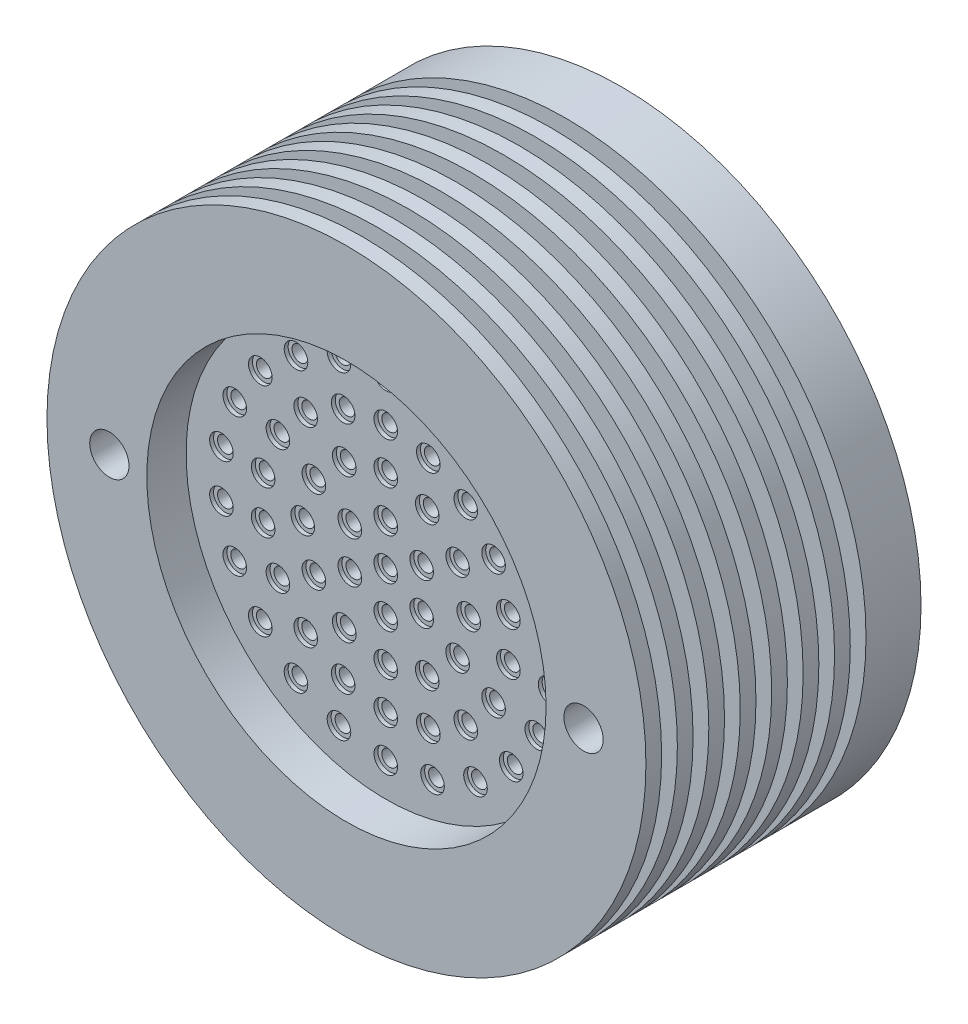
from build123d import *

# Parameters (mm, degrees)
ESQUISSE2_R                = 38.1
BOSS_EXTRU_1_DEPTH         = 35
ESQUISSE3_R                = 25.4
ENL_V_MAT_EXTRU_1_DEPTH    = 5
ESQUISSE4_R                = 25.4
ENL_V_MAT_EXTRU_2_DEPTH    = 25
ESQUISSE5_R                = 1
ENL_V_MAT_EXTRU_3_DEPTH    = 5
ESQUISSE6_R                = 1.5
ENL_V_MAT_EXTRU_4_DEPTH    = 0.5
ESQUISSE7_R                = 38.1
ESQUISSE7_R_2              = 34.925
ENL_V_MAT_EXTRU_5_DEPTH    = 2
R_P_TITION_LIN_AIRE1_COUNT = 7
R_P_TITION_LIN_AIRE1_PITCH = 4
ESQUISSE8_R                = 2.5
ENL_V_MAT_EXTRU_6_DEPTH    = 36


with BuildPart() as part:
    # Esquisse2 → Boss.-Extru.1 (new body)
    with BuildSketch(Plane.XY):
        with Locations((31.739876627, 14.618781351)):
            Circle(ESQUISSE2_R)
    extrude(amount=BOSS_EXTRU_1_DEPTH)

    # Esquisse3 → Enlèv. mat.-Extru.1 (cut)
    with BuildSketch(Plane.XY.offset(35)):
        with Locations((31.739876627, 14.618781351)):
            Circle(ESQUISSE3_R)
    extrude(amount=-ENL_V_MAT_EXTRU_1_DEPTH, mode=Mode.SUBTRACT)

    # Esquisse4 → Enlèv. mat.-Extru.2 (cut)
    with BuildSketch(Plane(origin=(0, 0, 0), x_dir=(-1, 0, 0), z_dir=(0, 0, -1))):
        with Locations((-31.739876627, 14.618781351)):
            Circle(ESQUISSE4_R)
    extrude(amount=-ENL_V_MAT_EXTRU_2_DEPTH, mode=Mode.SUBTRACT)

    # Esquisse5 → Enlèv. mat.-Extru.3 (cut)
    with BuildSketch(Plane.XY.offset(30)):
        with Locations((31.739876627, 14.618781351)):
            Circle(ESQUISSE5_R)
        with Locations((31.739876627, 19.898781351)):
            Circle(ESQUISSE5_R)
        with Locations((36.312490759, 17.258781351)):
            Circle(ESQUISSE5_R)
        with Locations((36.312490759, 11.978781351)):
            Circle(ESQUISSE5_R)
        with Locations((31.739876627, 9.338781351)):
            Circle(ESQUISSE5_R)
        with Locations((27.167262495, 11.978781351)):
            Circle(ESQUISSE5_R)
        with Locations((27.167262495, 17.258781351)):
            Circle(ESQUISSE5_R)
        with Locations((31.739876627, 25.178781351)):
            Circle(ESQUISSE5_R)
        with Locations((37.019876627, 23.764009615)):
            Circle(ESQUISSE5_R)
        with Locations((40.885104891, 19.898781351)):
            Circle(ESQUISSE5_R)
        with Locations((42.299876627, 14.618781351)):
            Circle(ESQUISSE5_R)
        with Locations((40.885104891, 9.338781351)):
            Circle(ESQUISSE5_R)
        with Locations((37.019876627, 5.473553087)):
            Circle(ESQUISSE5_R)
        with Locations((31.739876627, 4.058781351)):
            Circle(ESQUISSE5_R)
        with Locations((26.459876627, 5.473553087)):
            Circle(ESQUISSE5_R)
        with Locations((22.594648363, 9.338781351)):
            Circle(ESQUISSE5_R)
        with Locations((21.179876627, 14.618781351)):
            Circle(ESQUISSE5_R)
        with Locations((22.594648363, 19.898781351)):
            Circle(ESQUISSE5_R)
        with Locations((26.459876627, 23.764009615)):
            Circle(ESQUISSE5_R)
        with Locations((31.739876627, 30.458781351)):
            Circle(ESQUISSE5_R)
        with Locations((37.157475698, 29.503512464)):
            Circle(ESQUISSE5_R)
        with Locations((41.921632365, 26.75292533)):
            Circle(ESQUISSE5_R)
        with Locations((45.457719023, 22.538781351)):
            Circle(ESQUISSE5_R)
        with Locations((47.339231435, 17.369368485)):
            Circle(ESQUISSE5_R)
        with Locations((47.339231435, 11.868194217)):
            Circle(ESQUISSE5_R)
        with Locations((45.457719023, 6.698781351)):
            Circle(ESQUISSE5_R)
        with Locations((41.921632365, 2.484637372)):
            Circle(ESQUISSE5_R)
        with Locations((37.157475698, -0.265949762)):
            Circle(ESQUISSE5_R)
        with Locations((31.739876627, -1.221218649)):
            Circle(ESQUISSE5_R)
        with Locations((26.322277557, -0.265949762)):
            Circle(ESQUISSE5_R)
        with Locations((21.55812089, 2.484637372)):
            Circle(ESQUISSE5_R)
        with Locations((18.022034231, 6.698781351)):
            Circle(ESQUISSE5_R)
        with Locations((16.14052182, 11.868194217)):
            Circle(ESQUISSE5_R)
        with Locations((16.14052182, 17.369368485)):
            Circle(ESQUISSE5_R)
        with Locations((18.022034231, 22.538781351)):
            Circle(ESQUISSE5_R)
        with Locations((21.55812089, 26.75292533)):
            Circle(ESQUISSE5_R)
        with Locations((26.322277557, 29.503512464)):
            Circle(ESQUISSE5_R)
        with Locations((31.739876627, 35.738781351)):
            Circle(ESQUISSE5_R)
        with Locations((37.690068228, 34.883272954)):
            Circle(ESQUISSE5_R)
        with Locations((43.158210692, 32.386055965)):
            Circle(ESQUISSE5_R)
        with Locations((47.701307638, 28.449440052)):
            Circle(ESQUISSE5_R)
        with Locations((50.951304369, 23.392346426)):
            Circle(ESQUISSE5_R)
        with Locations((52.64490548, 17.624470735)):
            Circle(ESQUISSE5_R)
        with Locations((52.64490548, 11.613091967)):
            Circle(ESQUISSE5_R)
        with Locations((50.951304369, 5.845216277)):
            Circle(ESQUISSE5_R)
        with Locations((47.701307638, 0.78812265)):
            Circle(ESQUISSE5_R)
        with Locations((43.158210692, -3.148493262)):
            Circle(ESQUISSE5_R)
        with Locations((37.690068228, -5.645710252)):
            Circle(ESQUISSE5_R)
        with Locations((31.739876627, -6.501218649)):
            Circle(ESQUISSE5_R)
        with Locations((25.789685027, -5.645710252)):
            Circle(ESQUISSE5_R)
        with Locations((20.321542563, -3.148493262)):
            Circle(ESQUISSE5_R)
        with Locations((15.778445617, 0.78812265)):
            Circle(ESQUISSE5_R)
        with Locations((12.528448885, 5.845216277)):
            Circle(ESQUISSE5_R)
        with Locations((10.834847775, 11.613091967)):
            Circle(ESQUISSE5_R)
        with Locations((10.834847775, 17.624470735)):
            Circle(ESQUISSE5_R)
        with Locations((12.528448885, 23.392346426)):
            Circle(ESQUISSE5_R)
        with Locations((15.778445617, 28.449440052)):
            Circle(ESQUISSE5_R)
        with Locations((20.321542563, 32.386055965)):
            Circle(ESQUISSE5_R)
        with Locations((25.789685027, 34.883272954)):
            Circle(ESQUISSE5_R)
    extrude(amount=-ENL_V_MAT_EXTRU_3_DEPTH, mode=Mode.SUBTRACT)

    # Esquisse6 → Enlèv. mat.-Extru.4 (cut)
    with BuildSketch(Plane.XY.offset(30)):
        with Locations((31.739876627, 14.618781351)):
            Circle(ESQUISSE6_R)
        with Locations((31.739876627, 19.898781351)):
            Circle(ESQUISSE6_R)
        with Locations((36.312490759, 17.258781351)):
            Circle(ESQUISSE6_R)
        with Locations((36.312490759, 11.978781351)):
            Circle(ESQUISSE6_R)
        with Locations((31.739876627, 9.338781351)):
            Circle(ESQUISSE6_R)
        with Locations((27.167262495, 11.978781351)):
            Circle(ESQUISSE6_R)
        with Locations((27.167262495, 17.258781351)):
            Circle(ESQUISSE6_R)
        with Locations((31.739876627, 25.178781351)):
            Circle(ESQUISSE6_R)
        with Locations((37.019876627, 23.764009615)):
            Circle(ESQUISSE6_R)
        with Locations((40.885104891, 19.898781351)):
            Circle(ESQUISSE6_R)
        with Locations((42.299876627, 14.618781351)):
            Circle(ESQUISSE6_R)
        with Locations((40.885104891, 9.338781351)):
            Circle(ESQUISSE6_R)
        with Locations((37.019876627, 5.473553087)):
            Circle(ESQUISSE6_R)
        with Locations((31.739876627, 4.058781351)):
            Circle(ESQUISSE6_R)
        with Locations((26.459876627, 5.473553087)):
            Circle(ESQUISSE6_R)
        with Locations((22.594648363, 9.338781351)):
            Circle(ESQUISSE6_R)
        with Locations((21.179876627, 14.618781351)):
            Circle(ESQUISSE6_R)
        with Locations((22.594648363, 19.898781351)):
            Circle(ESQUISSE6_R)
        with Locations((26.459876627, 23.764009615)):
            Circle(ESQUISSE6_R)
        with Locations((31.739876627, 30.458781351)):
            Circle(ESQUISSE6_R)
        with Locations((31.739876627, 35.738781351)):
            Circle(ESQUISSE6_R)
        with Locations((37.690068228, 34.883272954)):
            Circle(ESQUISSE6_R)
        with Locations((43.158210692, 32.386055965)):
            Circle(ESQUISSE6_R)
        with Locations((47.701307638, 28.449440052)):
            Circle(ESQUISSE6_R)
        with Locations((50.951304369, 23.392346426)):
            Circle(ESQUISSE6_R)
        with Locations((52.64490548, 17.624470735)):
            Circle(ESQUISSE6_R)
        with Locations((52.64490548, 11.613091967)):
            Circle(ESQUISSE6_R)
        with Locations((50.951304369, 5.845216277)):
            Circle(ESQUISSE6_R)
        with Locations((47.701307638, 0.78812265)):
            Circle(ESQUISSE6_R)
        with Locations((43.158210692, -3.148493262)):
            Circle(ESQUISSE6_R)
        with Locations((37.690068228, -5.645710252)):
            Circle(ESQUISSE6_R)
        with Locations((31.739876627, -6.501218649)):
            Circle(ESQUISSE6_R)
        with Locations((25.789685027, -5.645710252)):
            Circle(ESQUISSE6_R)
        with Locations((20.321542563, -3.148493262)):
            Circle(ESQUISSE6_R)
        with Locations((15.778445617, 0.78812265)):
            Circle(ESQUISSE6_R)
        with Locations((12.528448885, 5.845216277)):
            Circle(ESQUISSE6_R)
        with Locations((10.834847775, 11.613091967)):
            Circle(ESQUISSE6_R)
        with Locations((10.834847775, 17.624470735)):
            Circle(ESQUISSE6_R)
        with Locations((12.528448885, 23.392346426)):
            Circle(ESQUISSE6_R)
        with Locations((15.778445617, 28.449440052)):
            Circle(ESQUISSE6_R)
        with Locations((20.321542563, 32.386055965)):
            Circle(ESQUISSE6_R)
        with Locations((25.789685027, 34.883272954)):
            Circle(ESQUISSE6_R)
        with Locations((37.157475698, 29.503512464)):
            Circle(ESQUISSE6_R)
        with Locations((41.921632365, 26.75292533)):
            Circle(ESQUISSE6_R)
        with Locations((45.457719023, 22.538781351)):
            Circle(ESQUISSE6_R)
        with Locations((47.339231435, 17.369368485)):
            Circle(ESQUISSE6_R)
        with Locations((47.339231435, 11.868194217)):
            Circle(ESQUISSE6_R)
        with Locations((45.457719023, 6.698781351)):
            Circle(ESQUISSE6_R)
        with Locations((41.921632365, 2.484637372)):
            Circle(ESQUISSE6_R)
        with Locations((37.157475698, -0.265949762)):
            Circle(ESQUISSE6_R)
        with Locations((31.739876627, -1.221218649)):
            Circle(ESQUISSE6_R)
        with Locations((26.322277557, -0.265949762)):
            Circle(ESQUISSE6_R)
        with Locations((21.55812089, 2.484637372)):
            Circle(ESQUISSE6_R)
        with Locations((18.022034231, 6.698781351)):
            Circle(ESQUISSE6_R)
        with Locations((16.14052182, 11.868194217)):
            Circle(ESQUISSE6_R)
        with Locations((16.14052182, 17.369368485)):
            Circle(ESQUISSE6_R)
        with Locations((18.022034231, 22.538781351)):
            Circle(ESQUISSE6_R)
        with Locations((21.55812089, 26.75292533)):
            Circle(ESQUISSE6_R)
        with Locations((26.322277557, 29.503512464)):
            Circle(ESQUISSE6_R)
    extrude(amount=-ENL_V_MAT_EXTRU_4_DEPTH, mode=Mode.SUBTRACT)

    # Esquisse7 → Enlèv. mat.-Extru.5 (cut)
    with BuildSketch(Plane.XY.offset(33)):
        with Locations((31.739876627, 14.618781351)):
            Circle(ESQUISSE7_R)
        with Locations((31.739876627, 14.618781351)):
            Circle(ESQUISSE7_R_2, mode=Mode.SUBTRACT)
    enl_v_mat_extru_5 = extrude(amount=-ENL_V_MAT_EXTRU_5_DEPTH, mode=Mode.SUBTRACT)

    # Répétition linéaire1: Enlèv. mat.-Extru.5 ×7
    with Locations(*[(0, 0, -i * R_P_TITION_LIN_AIRE1_PITCH) for i in range(1, R_P_TITION_LIN_AIRE1_COUNT)]):
        add(enl_v_mat_extru_5, mode=Mode.SUBTRACT)

    # Esquisse8 → Enlèv. mat.-Extru.6 (cut, through all)
    with BuildSketch(Plane(origin=(0, 0, 0), x_dir=(-1, 0, 0), z_dir=(0, 0, -1))):
        with Locations((-1.577376627, 14.618781351)):
            Circle(ESQUISSE8_R)
        with Locations((-61.902376627, 14.618781351)):
            Circle(ESQUISSE8_R)
    extrude(amount=-ENL_V_MAT_EXTRU_6_DEPTH, mode=Mode.SUBTRACT)


solid = part.part
